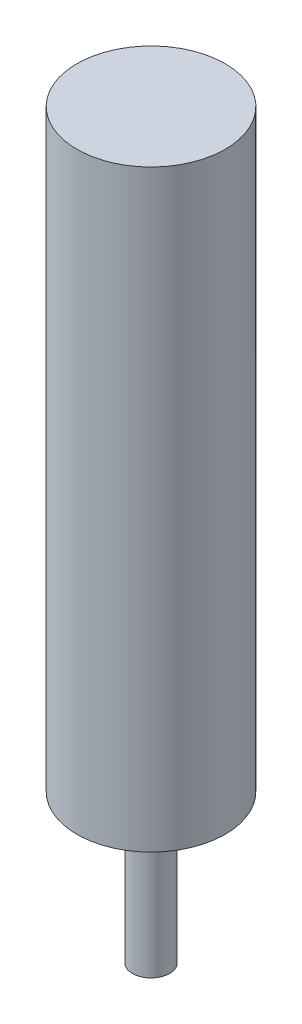
from build123d import *


with BuildPart() as part:
    # Sketch1 → Revolve1 (revolve)
    with BuildSketch(Plane.XY):
        Polygon((0, 63.5), (6.35, 63.5), (6.35, 12.7), (1.5875, 12.7), (1.5875, 0), (0, 0), align=None)
    revolve(axis=Axis((0, 0, 0), (0, 1, 0)))


solid = part.part
